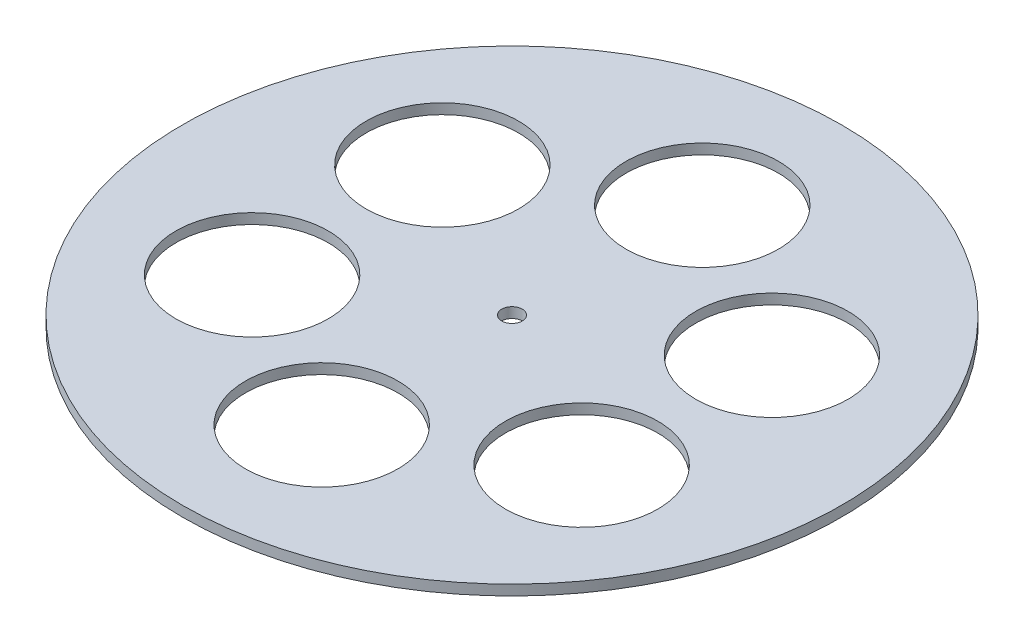
from build123d import *

# Parameters (mm, degrees)
SKETCH1_R           = 101.6
SKETCH1_R_2         = 3.175
SKETCH1_R_3         = 23.495
BOSS_EXTRUDE1_DEPTH = 3.175


with BuildPart() as part:
    # Sketch1 → Boss-Extrude1 (new body)
    with BuildSketch(Plane(origin=(0, 0, 0), x_dir=(1, 0, 0), z_dir=(0, 1, 0))):
        with Locations(Location((0, 0, 0), (0, 0, 270))):  # turned: the seam where the file's is
            Circle(SKETCH1_R)
        with Locations(Location((0, 0, 0), (0, 0, 270))):  # turned: the seam where the file's is
            Circle(SKETCH1_R_2, mode=Mode.SUBTRACT)
        with Locations(Location((0, 58.65878735, 0), (0, 0, 270))):  # turned: the seam where the file's is
            Circle(SKETCH1_R_3, mode=Mode.SUBTRACT)
        with Locations(Location((50.8, 29.329393675, 0), (0, 0, 270))):  # turned: the seam where the file's is
            Circle(SKETCH1_R_3, mode=Mode.SUBTRACT)
        with Locations(Location((50.8, -29.329393675, 0), (0, 0, 270))):  # turned: the seam where the file's is
            Circle(SKETCH1_R_3, mode=Mode.SUBTRACT)
        with Locations(Location((0, -58.65878735, 0), (0, 0, 270))):  # turned: the seam where the file's is
            Circle(SKETCH1_R_3, mode=Mode.SUBTRACT)
        with Locations(Location((-50.8, -29.329393675, 0), (0, 0, 270))):  # turned: the seam where the file's is
            Circle(SKETCH1_R_3, mode=Mode.SUBTRACT)
        with Locations(Location((-50.8, 29.329393675, 0), (0, 0, 270))):  # turned: the seam where the file's is
            Circle(SKETCH1_R_3, mode=Mode.SUBTRACT)
    extrude(amount=BOSS_EXTRUDE1_DEPTH)


solid = part.part
